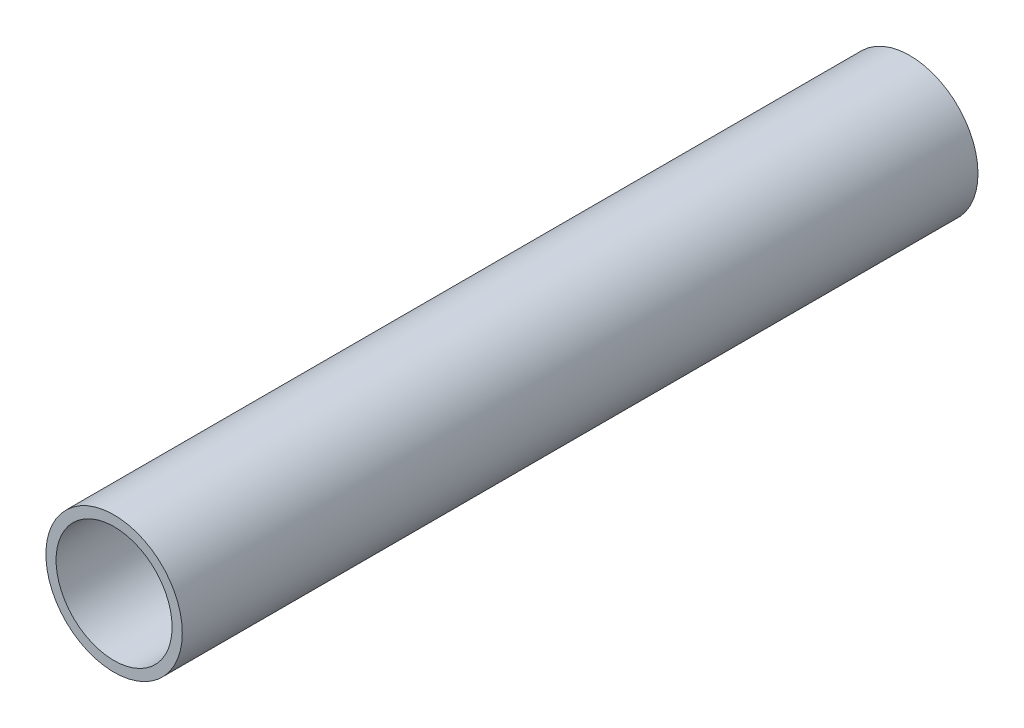
from build123d import *

# Parameters (mm, degrees)
SKETCH1_R      = 4.7625
SKETCH1_R_2    = 4.0513
EXTRUDE1_DEPTH = 27.78125


with BuildPart() as part:
    # Sketch1 → Extrude1 (new body, symmetric)
    with BuildSketch(Plane.XY):
        Circle(SKETCH1_R)
        Circle(SKETCH1_R_2, mode=Mode.SUBTRACT)
    extrude(amount=EXTRUDE1_DEPTH, both=True)


solid = part.part
